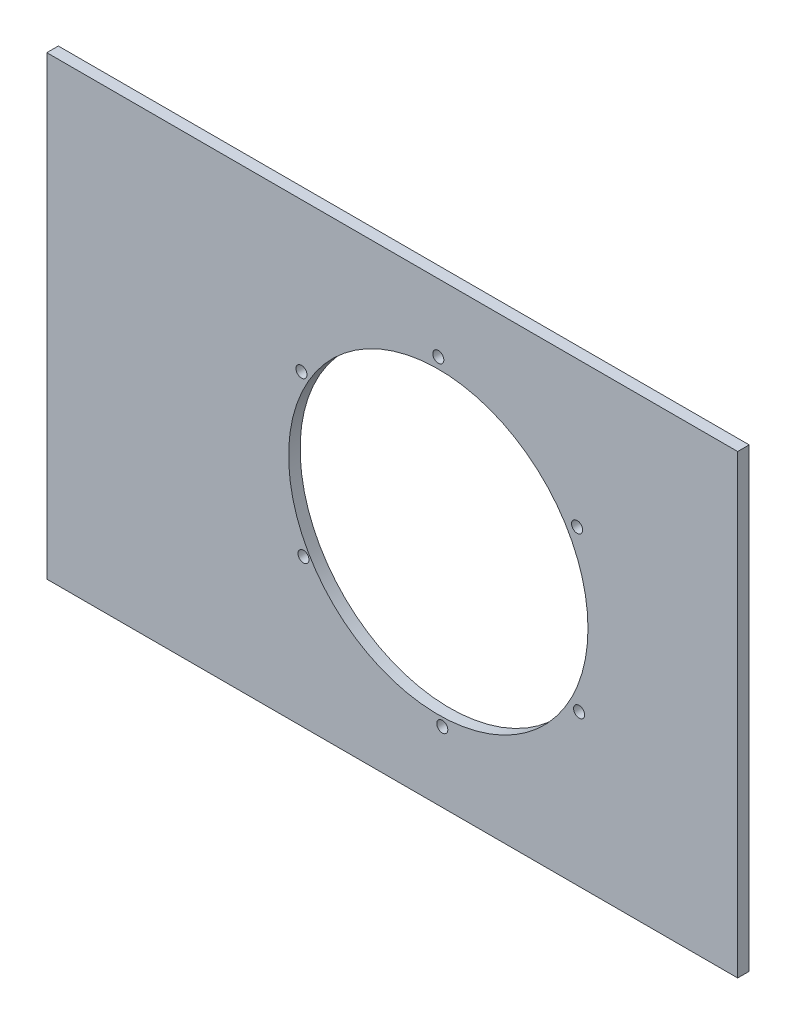
from build123d import *

# Parameters (mm, degrees)
SKETCH1_W           = 381
SKETCH1_H           = 251.46
SKETCH1_R           = 82.55
SKETCH1_R_2         = 3.048
BOSS_EXTRUDE1_DEPTH = 6.35


with BuildPart() as part:
    # Sketch1 → Boss-Extrude1 (new body)
    with BuildSketch(Plane.XY):
        with Locations((-190.5, 125.73)):
            Rectangle(SKETCH1_W, SKETCH1_H)
        with Locations((-165.1, 125.73)):
            Circle(SKETCH1_R, mode=Mode.SUBTRACT)
        with Locations((-165.1, 214.122)):
            Circle(SKETCH1_R_2, mode=Mode.SUBTRACT)
        with Locations((-88.550282509, 171.196)):
            Circle(SKETCH1_R_2, mode=Mode.SUBTRACT)
        with Locations((-87.450430246, 83.439)):
            Circle(SKETCH1_R_2, mode=Mode.SUBTRACT)
        with Locations((-162.900295474, 38.608)):
            Circle(SKETCH1_R_2, mode=Mode.SUBTRACT)
        with Locations((-239.450012966, 81.534)):
            Circle(SKETCH1_R_2, mode=Mode.SUBTRACT)
        with Locations((-240.549865229, 169.291)):
            Circle(SKETCH1_R_2, mode=Mode.SUBTRACT)
    extrude(amount=BOSS_EXTRUDE1_DEPTH)


solid = part.part
